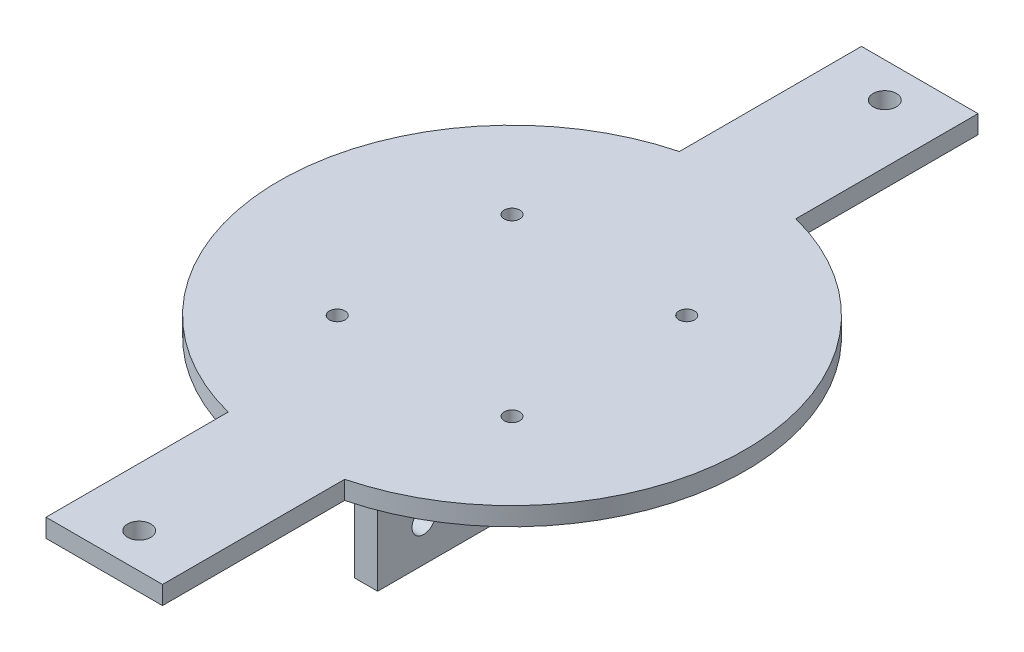
from build123d import *

# Parameters (mm, degrees)
BOSS_EXTRUDE1_DEPTH  = 4
SKETCH3_W            = 5
SKETCH3_H            = 88.9
BOSS_EXTRUDE2_DEPTH  = 18.288
M3_CLEARANCE_HOLE1_D = 3.4
FILLET1_R            = 0.5
SKETCH6_R            = 2.54
CUT_EXTRUDE1_DEPTH   = 66.96
SKETCH7_R            = 2.54
CUT_EXTRUDE2_DEPTH   = 23.288


with BuildPart() as part:
    # Sketch1 → Boss-Extrude1 (new body)
    with BuildSketch(Plane(origin=(0, 0, 0), x_dir=(1, 0, 0), z_dir=(0, 1, 0))):
        with BuildLine():
            Line((-12.7, 49.186888497), (-12.7, 88.9))
            Line((-12.7, 88.9), (12.7, 88.9))
            Line((12.7, 88.9), (12.7, 49.186888497))
            ThreePointArc((12.7, 49.186888497), (50.8, 0), (12.7, -49.186888497))
            Line((12.7, -49.186888497), (12.7, -88.9))
            Line((12.7, -88.9), (-12.7, -88.9))
            Line((-12.7, -88.9), (-12.7, -49.186888497))
            ThreePointArc((-12.7, -49.186888497), (-50.8, 0), (-12.7, 49.186888497))
        make_face()
    extrude(amount=BOSS_EXTRUDE1_DEPTH)

    # Sketch3 → Boss-Extrude2 (add)
    with BuildSketch(Plane(origin=(0, 0, 0), x_dir=(-1, 0, 0), z_dir=(0, -1, 0))):
        with Locations((12.66, 0)):
            Rectangle(SKETCH3_W, SKETCH3_H)
        with Locations((-12.66, 0)):
            Rectangle(SKETCH3_W, SKETCH3_H)
    extrude(amount=BOSS_EXTRUDE2_DEPTH)

    # M3 Clearance Hole1 (through all)
    with Locations(Plane(origin=(0, 4, 0), x_dir=(1, 0, 0), z_dir=(0, 1, 0))):
        with Locations((-19.05, -19.05), (19.05, -19.05), (-19.05, 19.05), (19.05, 19.05)):
            Hole(M3_CLEARANCE_HOLE1_D / 2)

    # Fillet1
    fillet1_edges = [part.edges().sort_by_distance(p)[0] for p in [
        (-15.16, 0, 0),
        (-12.66, 0, -44.45),
        (-12.66, 0, 44.45),
        (12.66, 0, -44.45),
        (15.16, 0, 0),
        (12.66, 0, 44.45),
    ]]
    fillet(fillet1_edges, radius=FILLET1_R)

    # Sketch6 → Cut-Extrude1 (cut, through all)
    with BuildSketch(Plane.ZY.offset(15.16)):
        with Locations((34.417, -10.033)):
            Circle(SKETCH6_R)
        with Locations((-34.417, -10.033)):
            Circle(SKETCH6_R)
    extrude(amount=-CUT_EXTRUDE1_DEPTH, mode=Mode.SUBTRACT)

    # Sketch7 → Cut-Extrude2 (cut, through all)
    with BuildSketch(Plane(origin=(0, 4, 0), x_dir=(1, 0, 0), z_dir=(0, 1, 0))):
        with Locations((0, 81.28)):
            Circle(SKETCH7_R)
        with Locations((0, -81.28)):
            Circle(SKETCH7_R)
    extrude(amount=-CUT_EXTRUDE2_DEPTH, mode=Mode.SUBTRACT)


solid = part.part
